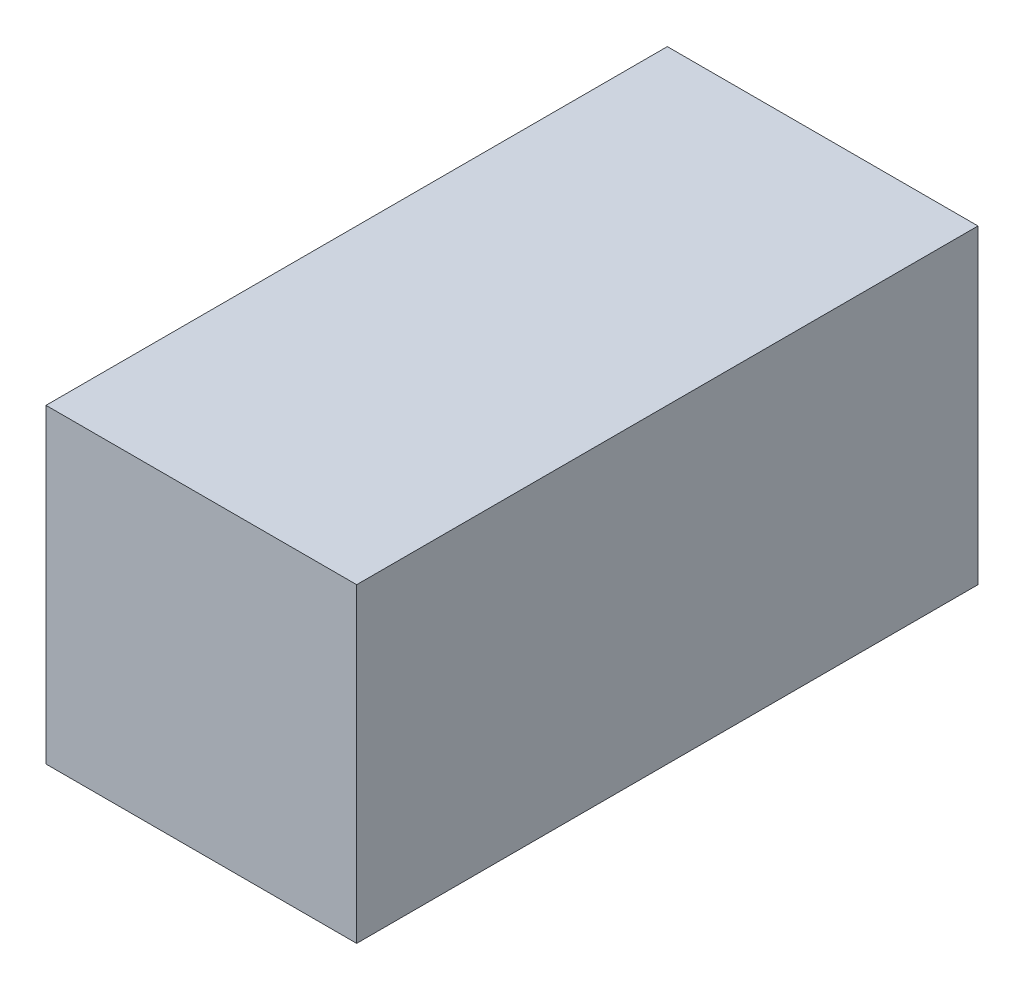
from build123d import *

# Parameters (mm, degrees)
ESQUISSE1_W      = 22
ESQUISSE1_H      = 22
EXTRUSION1_DEPTH = 44


with BuildPart() as part:
    # Esquisse1 → Extrusion1 (new body)
    with BuildSketch(Plane.XY):
        with Locations((11, 11)):
            Rectangle(ESQUISSE1_W, ESQUISSE1_H)
    extrude(amount=-EXTRUSION1_DEPTH)


solid = part.part
